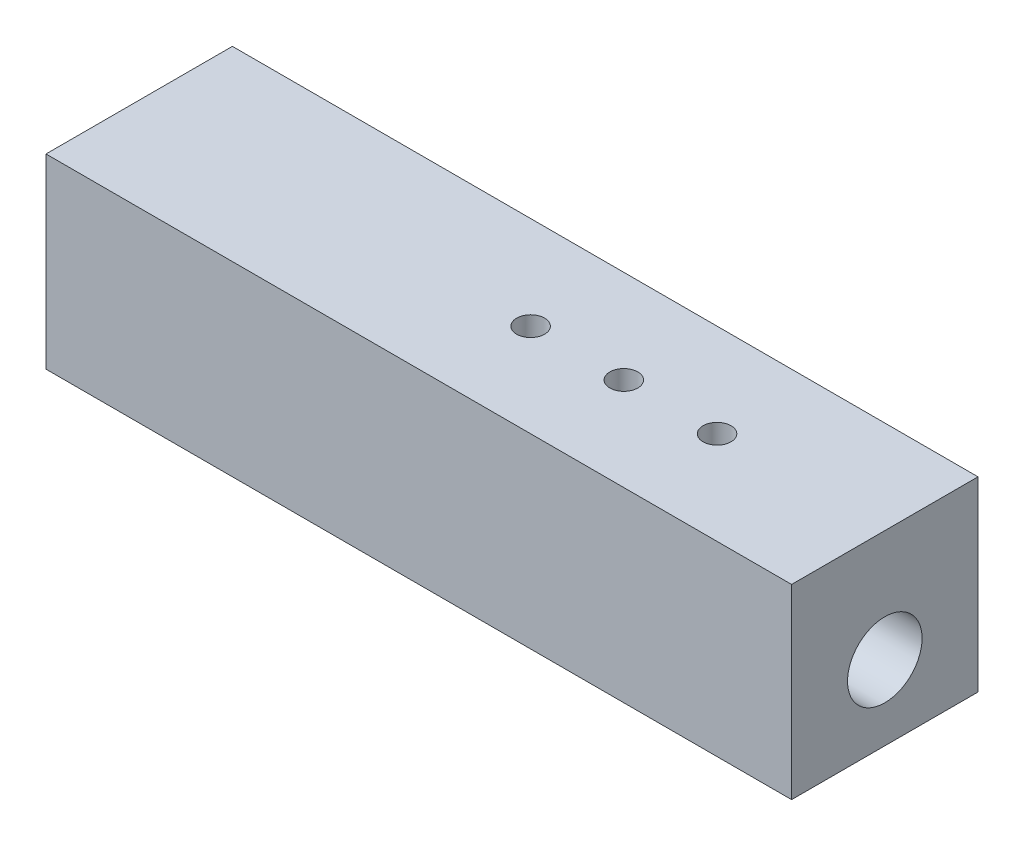
from build123d import *

# Parameters (mm, degrees)
SKETCH1_W           = 40
SKETCH1_H           = 10
BOSS_EXTRUDE1_DEPTH = 10
SKETCH2_R           = 2
CUT_EXTRUDE1_DEPTH  = 41
CUT_EXTRUDE2_REACH  = 12
SKETCH3_R           = 0.75


with BuildPart() as part:
    # Sketch1 → Boss-Extrude1 (new body)
    with BuildSketch(Plane(origin=(0, 0, 0), x_dir=(1, 0, 0), z_dir=(0, 1, 0))):
        Rectangle(SKETCH1_W, SKETCH1_H)
    extrude(amount=BOSS_EXTRUDE1_DEPTH)

    # Sketch2 → Cut-Extrude1 (cut, through all)
    with BuildSketch(Plane(origin=(20, 0, 0), x_dir=(0, 0, -1), z_dir=(1, 0, 0))):
        with Locations((0, 4)):
            Circle(SKETCH2_R)
    extrude(amount=-CUT_EXTRUDE1_DEPTH, mode=Mode.SUBTRACT)

    # Sketch3 → Cut-Extrude2 (cut, up to next)
    with BuildSketch(Plane(origin=(0, 10, 0), x_dir=(1, 0, 0), z_dir=(0, 1, 0)), mode=Mode.PRIVATE) as cut_extrude2_sk1:
        with Locations((11, 0)):
            Circle(SKETCH3_R)
    cut_extrude2_tool1 = extrude(cut_extrude2_sk1.sketch, amount=-CUT_EXTRUDE2_REACH, mode=Mode.PRIVATE) & part.part
    add(cut_extrude2_tool1.solids().sort_by_distance((11, 10, 0))[0], mode=Mode.SUBTRACT)
    # Sketch3 → Cut-Extrude2 (cut, up to next)
    with BuildSketch(Plane(origin=(0, 10, 0), x_dir=(1, 0, 0), z_dir=(0, 1, 0)), mode=Mode.PRIVATE) as cut_extrude2_sk2:
        with Locations((6, 0)):
            Circle(SKETCH3_R)
    cut_extrude2_tool2 = extrude(cut_extrude2_sk2.sketch, amount=-CUT_EXTRUDE2_REACH, mode=Mode.PRIVATE) & part.part
    add(cut_extrude2_tool2.solids().sort_by_distance((6, 10, 0))[0], mode=Mode.SUBTRACT)
    # Sketch3 → Cut-Extrude2 (cut, up to next)
    with BuildSketch(Plane(origin=(0, 10, 0), x_dir=(1, 0, 0), z_dir=(0, 1, 0)), mode=Mode.PRIVATE) as cut_extrude2_sk3:
        with Locations((1, 0)):
            Circle(SKETCH3_R)
    cut_extrude2_tool3 = extrude(cut_extrude2_sk3.sketch, amount=-CUT_EXTRUDE2_REACH, mode=Mode.PRIVATE) & part.part
    add(cut_extrude2_tool3.solids().sort_by_distance((1, 10, 0))[0], mode=Mode.SUBTRACT)


solid = part.part
